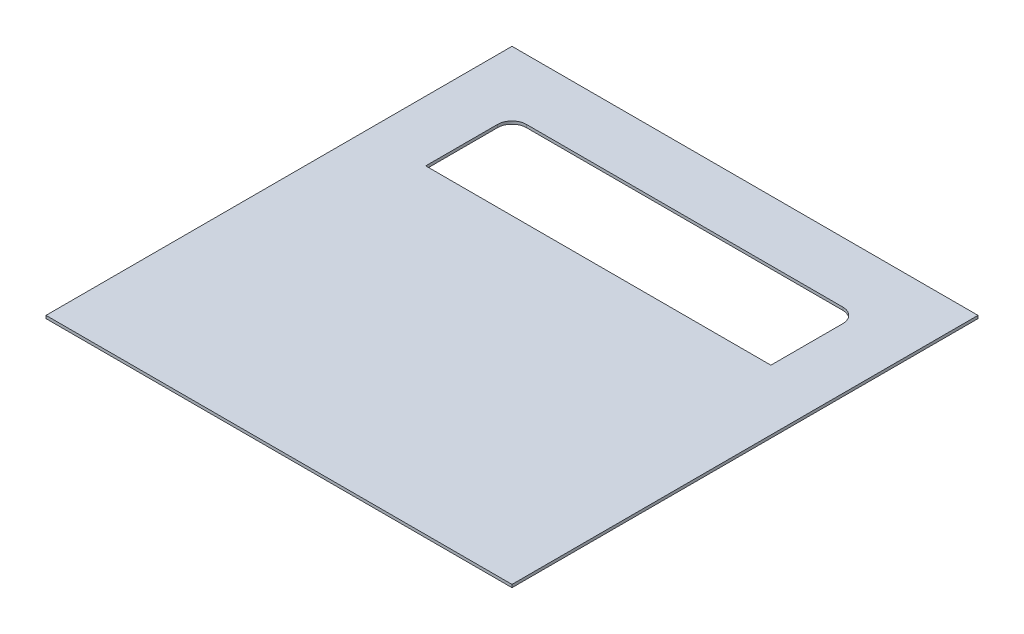
from build123d import *

# Parameters (mm, degrees)
SKETCH_1_W          = 162
SKETCH_1_H          = 162
EXTRUDE_1_DEPTH     = 1
CUT_EXTRUDE_1_REACH = 3
SKETCH_2_W          = 120
SKETCH_2_H          = 30
FILLET_1_R          = 5


with BuildPart() as part:
    # 草图1 → 凸台-拉伸1 (new body)
    with BuildSketch(Plane(origin=(0, 0, 0), x_dir=(1, 0, 0), z_dir=(0, 1, 0))):
        Rectangle(SKETCH_1_W, SKETCH_1_H)
    extrude(amount=EXTRUDE_1_DEPTH)

    # 草图2 → 切除-拉伸1 (cut, up to next)
    with BuildSketch(Plane.XZ, mode=Mode.PRIVATE) as cut_extrude_1_sk1:
        with Locations((0, -45)):
            Rectangle(SKETCH_2_W, SKETCH_2_H)
    cut_extrude_1_tool1 = extrude(cut_extrude_1_sk1.sketch, amount=-CUT_EXTRUDE_1_REACH, mode=Mode.PRIVATE) & part.part
    add(cut_extrude_1_tool1.solids().sort_by_distance((0, 0, -45))[0], mode=Mode.SUBTRACT)

    # 圆角1
    fillet_1_edges = [part.edges().sort_by_distance(p)[0] for p in [
        (60, 0.5, -60),
        (-60, 0.5, -60),
    ]]
    fillet(fillet_1_edges, radius=FILLET_1_R)


solid = part.part
